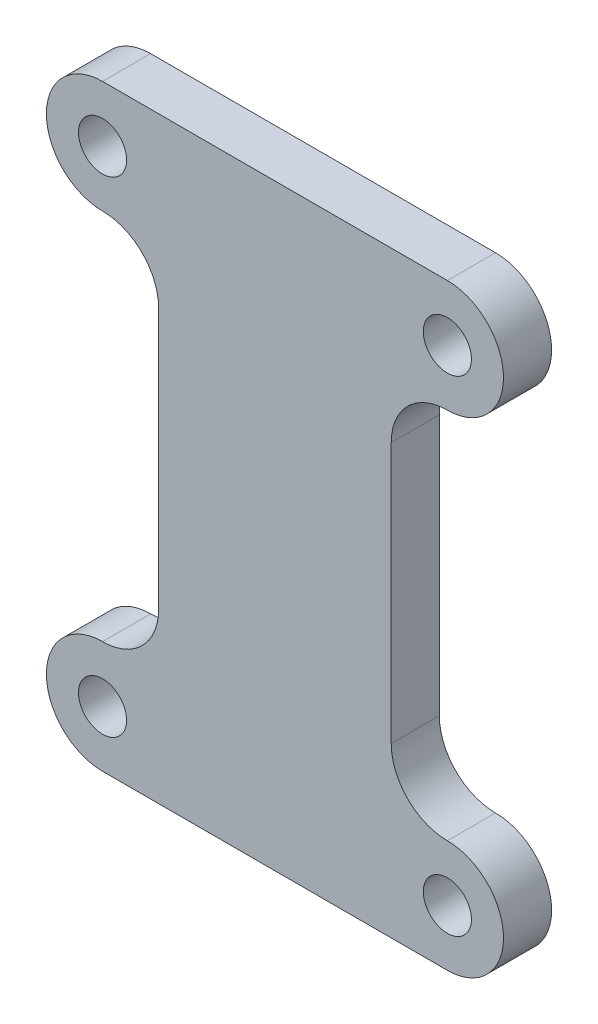
from build123d import *

# Parameters (mm, degrees)
SKETCH1_R           = 1.5
BOSS_EXTRUDE1_DEPTH = 1.5


with BuildPart() as part:
    # Sketch1 → Boss-Extrude1 (new body, symmetric)
    with BuildSketch(Plane.XY):
        with BuildLine():
            Line((-10.75, 18.625), (10.75, 18.625))
            ThreePointArc((10.75, 18.625), (14.25, 15.125), (10.75, 11.625))
            ThreePointArc((10.75, 11.625), (8.275126266, 10.599873734), (7.25, 8.125))
            Line((7.25, 8.125), (7.25, -8.125))
            ThreePointArc((7.25, -8.125), (8.275126266, -10.599873734), (10.75, -11.625))
            ThreePointArc((10.75, -11.625), (14.25, -15.125), (10.75, -18.625))
            Line((10.75, -18.625), (-10.75, -18.625))
            ThreePointArc((-10.75, -18.625), (-14.25, -15.125), (-10.75, -11.625))
            ThreePointArc((-10.75, -11.625), (-8.275126266, -10.599873734), (-7.25, -8.125))
            Line((-7.25, -8.125), (-7.25, 8.125))
            ThreePointArc((-7.25, 8.125), (-8.275126266, 10.599873734), (-10.75, 11.625))
            ThreePointArc((-10.75, 11.625), (-14.25, 15.125), (-10.75, 18.625))
        make_face()
        with Locations((-10.75, 15.125)):
            Circle(SKETCH1_R, mode=Mode.SUBTRACT)
        with Locations((10.75, 15.125)):
            Circle(SKETCH1_R, mode=Mode.SUBTRACT)
        with Locations((10.75, -15.125)):
            Circle(SKETCH1_R, mode=Mode.SUBTRACT)
        with Locations((-10.75, -15.125)):
            Circle(SKETCH1_R, mode=Mode.SUBTRACT)
    extrude(amount=BOSS_EXTRUDE1_DEPTH, both=True)


solid = part.part
